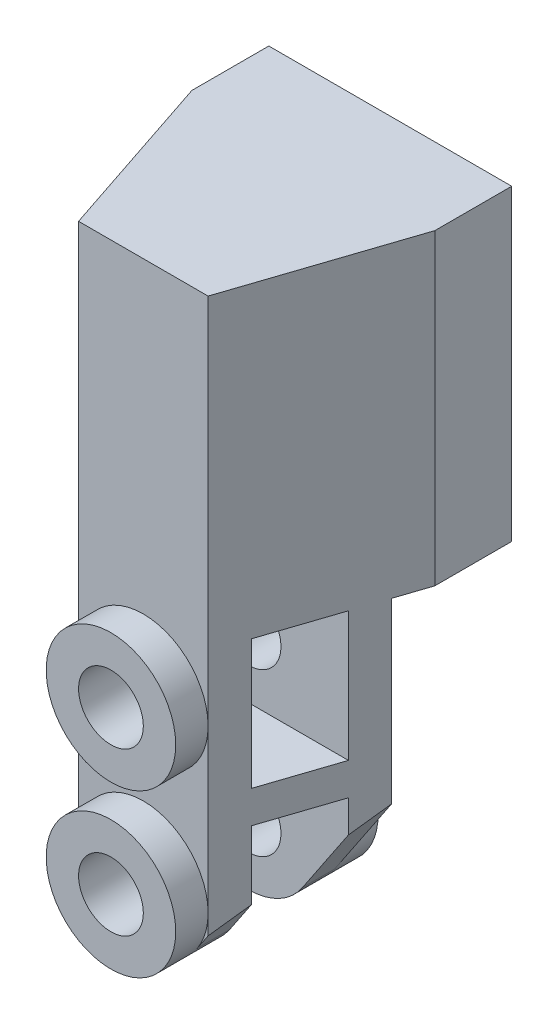
from build123d import *

# Parameters (mm, degrees)
BOSS_EXTRUDE1_DEPTH     = 24.209375
CUT_EXTRUDE1_DEPTH      = 65.637036854
CUT_EXTRUDE2_DEPTH      = 65.637036854
SKETCH4_R               = 3.175
CUT_EXTRUDE3_DEPTH      = 65.637036854
SKETCH5_W               = 7.14375
SKETCH5_H               = 12.7
SKETCH5_W_2             = 10.715625
SKETCH5_H_2             = 28.575
CUT_EXTRUDE4_DEPTH      = 65.637036854
CUT_EXTRUDE4_DEPTH_BACK = 65.637036854
SKETCH6_R               = 6.35
SKETCH6_R_2             = 3.175
BOSS_EXTRUDE2_DEPTH     = 3.175
SKETCH7_R               = 6.35
SKETCH7_R_2             = 3.175
BOSS_EXTRUDE4_DEPTH     = 3.175


with BuildPart() as part:
    # Sketch1 → Boss-Extrude1 (new body)
    with BuildSketch(Plane.XY):
        Polygon((-11.90625, 0), (11.90625, 0), (11.90625, -25.4), (11.90625, -58.7375), (-11.90625, -58.7375), (-11.90625, -25.4), align=None)
    extrude(amount=BOSS_EXTRUDE1_DEPTH)

    # Sketch2 → Cut-Extrude1 (cut, through all)
    with BuildSketch(Plane.XZ.offset(58.7375)):
        Polygon((-11.90625, 24.209375), (-11.90625, 7.540625), (-6.35, 24.209375), align=None)
        Polygon((11.90625, 24.209375), (6.35, 24.209375), (11.90625, 7.540625), align=None)
    extrude(amount=-CUT_EXTRUDE1_DEPTH, mode=Mode.SUBTRACT)

    # Sketch3 → Cut-Extrude2 (cut, through all)
    with BuildSketch(Plane.XY.offset(24.209375)):
        Polygon((-11.90625, -58.7375), (-6.35, -58.7375), (-6.35, -54.320108696), (-11.90625, -46.0375), align=None)
        Polygon((11.90625, -46.0375), (6.35, -54.320108696), (6.35, -58.7375), (11.90625, -58.7375), align=None)
        with BuildLine():
            Line((6.35, -54.320108696), (5.273356401, -55.925043253))
            ThreePointArc((5.273356401, -55.925043253), (2.988235294, -57.990441176), (0, -58.7375))
            Line((0, -58.7375), (6.35, -58.7375))
            Line((6.35, -58.7375), (6.35, -54.320108696))
        make_face()
        with BuildLine():
            Line((-6.35, -58.7375), (0, -58.7375))
            ThreePointArc((0, -58.7375), (-2.988235294, -57.990441176), (-5.273356401, -55.925043253))
            Line((-5.273356401, -55.925043253), (-6.35, -54.320108696))
            Line((-6.35, -54.320108696), (-6.35, -58.7375))
        make_face()
    extrude(amount=-CUT_EXTRUDE2_DEPTH, mode=Mode.SUBTRACT)

    # Sketch4 → Cut-Extrude3 (cut, through all)
    with BuildSketch(Plane.XY.offset(24.209375)):
        with Locations((0, -52.3875)):
            Circle(SKETCH4_R)
        with Locations((0, -36.5125)):
            Circle(SKETCH4_R)
    extrude(amount=-CUT_EXTRUDE3_DEPTH, mode=Mode.SUBTRACT)

    # Sketch5 → Cut-Extrude4 (cut, two sides)
    with BuildSketch(Plane(origin=(0, 0, 0), x_dir=(0, 0, -1), z_dir=(1, 0, 0))) as cut_extrude4_sk:
        with Locations((-17.4625, -52.3875)):
            Rectangle(SKETCH5_W, SKETCH5_H)
        with Locations((-17.4625, -36.5125)):
            Rectangle(SKETCH5_W, SKETCH5_H)
        with Locations((-5.3578125, -44.45)):
            Rectangle(SKETCH5_W_2, SKETCH5_H_2)
    extrude(amount=CUT_EXTRUDE4_DEPTH, mode=Mode.SUBTRACT)
    extrude(cut_extrude4_sk.sketch, amount=-CUT_EXTRUDE4_DEPTH_BACK, mode=Mode.SUBTRACT)

    # Sketch6 → Boss-Extrude2 (add)
    with BuildSketch(Plane.XY.offset(24.209375)):
        with Locations((0, -36.5125)):
            Circle(SKETCH6_R)
        with Locations((0, -36.5125)):
            Circle(SKETCH6_R_2, mode=Mode.SUBTRACT)
        with Locations((0, -52.3875)):
            Circle(SKETCH6_R)
        with Locations((0, -52.3875)):
            Circle(SKETCH6_R_2, mode=Mode.SUBTRACT)
    extrude(amount=BOSS_EXTRUDE2_DEPTH)

    # Sketch7 → Boss-Extrude4 (add)
    with BuildSketch(Plane(origin=(0, 0, 10.715625), x_dir=(-1, 0, 0), z_dir=(0, 0, -1))):
        with Locations(Location((0, -52.3875, 0), (0, 0, 213.855026128))):
            Circle(SKETCH7_R)
        with Locations(Location((0, -52.3875, 0), (0, 0, 180))):
            Circle(SKETCH7_R_2, mode=Mode.SUBTRACT)
        with BuildLine():
            Line((-3.175, -30.1625), (-3.175, -31.013238686))
            ThreePointArc((-3.175, -31.013238686), (0, -42.8625), (3.175, -31.013238686))
            Line((3.175, -31.013238686), (3.175, -30.1625))
            Line((3.175, -30.1625), (-3.175, -30.1625))
        make_face()
        with Locations(Location((0, -36.5125, 0), (0, 0, 180))):
            Circle(SKETCH7_R_2, mode=Mode.SUBTRACT)
    extrude(amount=BOSS_EXTRUDE4_DEPTH)


solid = part.part
